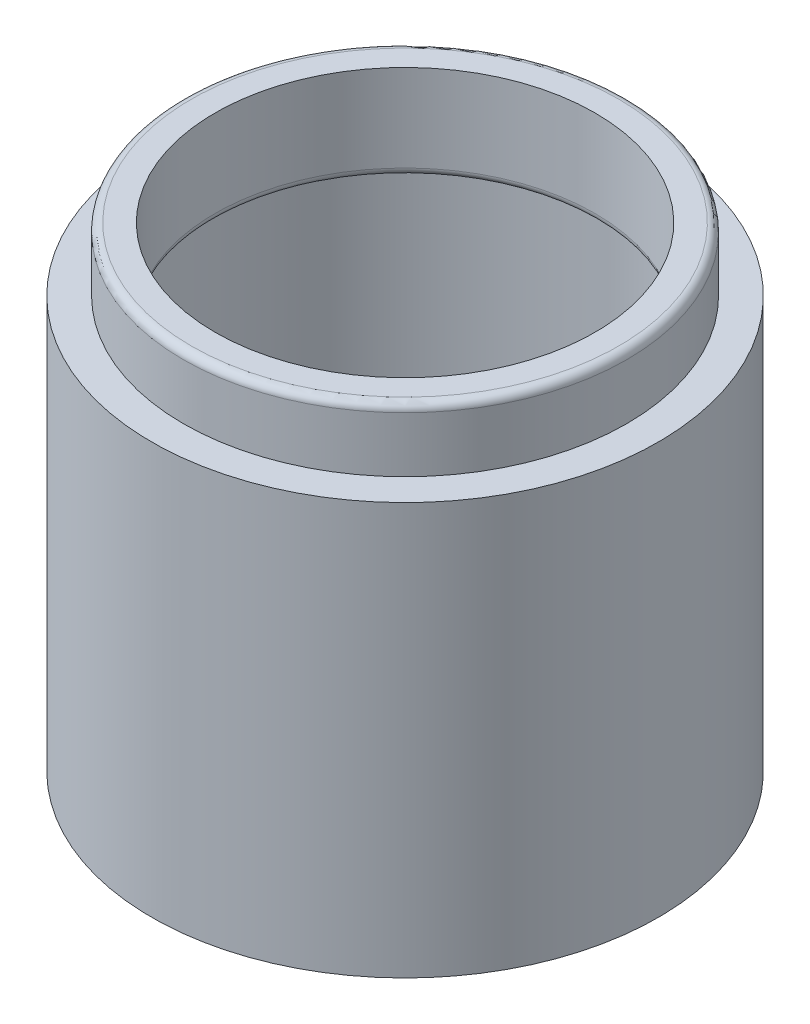
from build123d import *

# Parameters (mm, degrees)
FILLET1_R           = 0.79375
SKETCH2_W           = 6.35
SKETCH2_H           = 25.200781238
BOSS_EXTRUDE1_DEPTH = 3.175
FILLET2_R           = 1.5875


with BuildPart() as part:
    # Sketch1 → Revolve1 (revolve)
    with BuildSketch(Plane(origin=(0, 0, 0), x_dir=(0, 0, -1), z_dir=(1, 0, 0))):
        Polygon((22.225, 23.8125), (22.225, 17.4625), (25.4, 17.4625), (25.4, -23.8125), (22.225, -23.8125), (22.225, -17.4625), (9.525, -17.4625), (9.525, -14.2875), (22.4, -14.2875), (22.4, 14.2875), (19.05, 14.2875), (19.05, 23.8125), align=None)
    revolve(axis=Axis((0, -32.325211936, 0), (0, 1, 0)))

    # Fillet1
    fillet1_edges = [part.edges().sort_by_distance(p)[0] for p in [
        (0, -14.2875, 9.525),
        (0, -17.4625, 9.525),
        (0, -17.4625, 22.225),
        (0, -23.8125, 22.225),
        (0, 23.8125, 22.225),
        (0, 14.2875, 19.05),
    ]]
    fillet(fillet1_edges, radius=FILLET1_R)

    # Sketch2 → Boss-Extrude1 (add)
    with BuildSketch(Plane(origin=(0, -14.2875, 0), x_dir=(1, 0, 0), z_dir=(0, 1, 0))):
        with Locations((0, 12.600390619)):
            Rectangle(SKETCH2_W, SKETCH2_H)
    extrude(amount=-BOSS_EXTRUDE1_DEPTH)

    # Fillet2
    fillet2_edges = [part.edges().sort_by_distance(p)[0] for p in [
        (3.175, -15.875, 0),
        (-3.175, -15.875, 0),
    ]]
    fillet(fillet2_edges, radius=FILLET2_R)


solid = part.part
